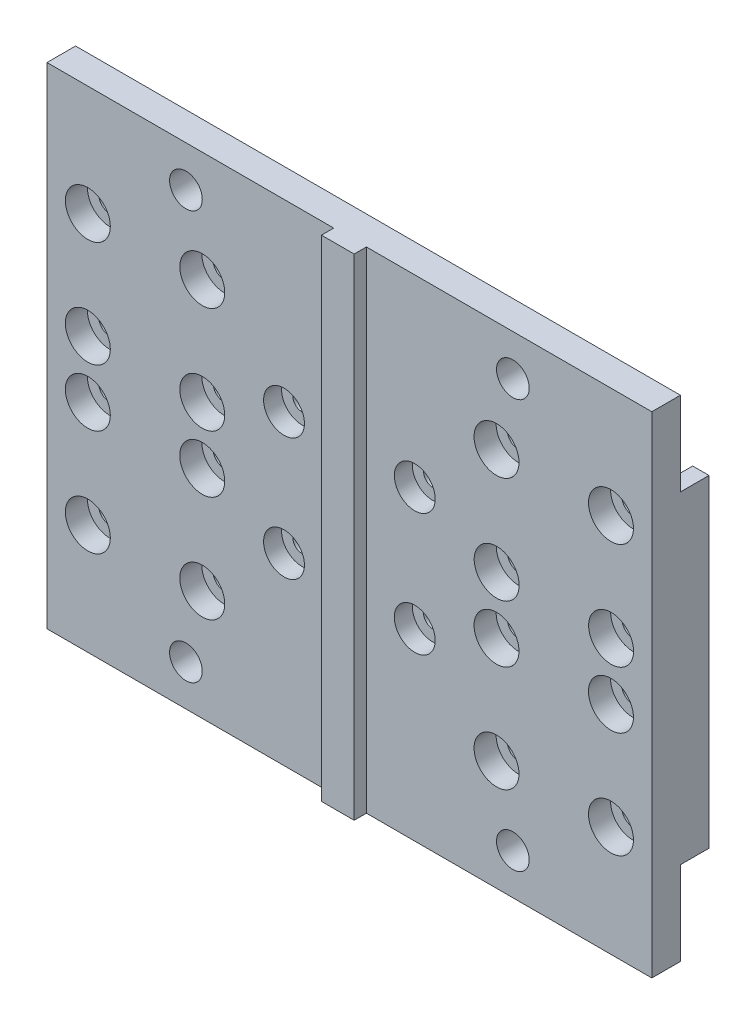
from build123d import *

# Parameters (mm, degrees)
ESQUISSE1_W                                        = 148
ESQUISSE1_H                                        = 120
ESQUISSE1_R                                        = 2.5
ESQUISSE1_R_2                                      = 2
EXTRUSION1_DEPTH                                   = 4
ESQUISSE2_R                                        = 4
ENL_V_MAT_EXTRU_1_DEPTH                            = 100.49847838
ESQUISSE3_W                                        = 148
ESQUISSE3_H                                        = 120
BOSS_EXTRU_1_DEPTH                                 = 3
CHAMBRAGE_POUR_VIS_T_TE_HEXAGONALE_M41_D           = 4.5
CHAMBRAGE_POUR_VIS_T_TE_HEXAGONALE_M41_CBORE_D     = 10
CHAMBRAGE_POUR_VIS_T_TE_HEXAGONALE_M41_CBORE_DEPTH = 4.4
CHAMBRAGE_POUR_VIS_T_TE_HEXAGONALE_M51_D           = 5.5
CHAMBRAGE_POUR_VIS_T_TE_HEXAGONALE_M51_CBORE_D     = 11
CHAMBRAGE_POUR_VIS_T_TE_HEXAGONALE_M51_CBORE_DEPTH = 5.4
ESQUISSE8_R                                        = 4
ENL_V_MAT_EXTRU_2_DEPTH                            = 100.664172098
BOSS_EXTRU_2_START                                 = 4
ESQUISSE9_W                                        = 148
ESQUISSE9_H                                        = 120
ESQUISSE9_R                                        = 2.75
ESQUISSE9_R_2                                      = 2.25
BOSS_EXTRU_2_DEPTH                                 = 4
ESQUISSE11_W                                       = 8
ESQUISSE11_H                                       = 120
BOSS_EXTRU_4_DEPTH                                 = 3
ESQUISSE12_R                                       = 4
ENL_V_MAT_EXTRU_3_DEPTH                            = 100.919703762
ESQUISSE13_R                                       = 2.75
ENL_V_MAT_EXTRU_4_DEPTH                            = 100.919703762
ESQUISSE14_W                                       = 148
ESQUISSE14_H                                       = 20.5
ENL_V_MAT_EXTRU_5_DEPTH                            = 4
ESQUISSE15_W                                       = 4
ESQUISSE15_H                                       = 79
ESQUISSE15_W_2                                     = 10
BOSS_EXTRU_5_DEPTH                                 = 3


with BuildPart() as part:
    # Esquisse1 → Extrusion1 (new body)
    with BuildSketch(Plane.XY):
        with Locations((0, 6.392373056)):
            Rectangle(ESQUISSE1_W, ESQUISSE1_H)
        with Locations((-64, -0.607626944)):
            Circle(ESQUISSE1_R, mode=Mode.SUBTRACT)
        with Locations((-36, 39.392373056)):
            Circle(ESQUISSE1_R, mode=Mode.SUBTRACT)
        with Locations((-64, -26.607626944)):
            Circle(ESQUISSE1_R, mode=Mode.SUBTRACT)
        with Locations((-36, -26.607626944)):
            Circle(ESQUISSE1_R, mode=Mode.SUBTRACT)
        with Locations((36, -0.607626944)):
            Circle(ESQUISSE1_R, mode=Mode.SUBTRACT)
        with Locations((64, -0.607626944)):
            Circle(ESQUISSE1_R, mode=Mode.SUBTRACT)
        with Locations((36, -26.607626944)):
            Circle(ESQUISSE1_R, mode=Mode.SUBTRACT)
        with Locations((64, -26.607626944)):
            Circle(ESQUISSE1_R, mode=Mode.SUBTRACT)
        with Locations((-36, -0.607626944)):
            Circle(ESQUISSE1_R, mode=Mode.SUBTRACT)
        with Locations((-64, 39.392373056)):
            Circle(ESQUISSE1_R, mode=Mode.SUBTRACT)
        with Locations((16, 21.392373056)):
            Circle(ESQUISSE1_R_2, mode=Mode.SUBTRACT)
        with Locations((16, -8.607626944)):
            Circle(ESQUISSE1_R_2, mode=Mode.SUBTRACT)
        with Locations((-16, 21.392373056)):
            Circle(ESQUISSE1_R_2, mode=Mode.SUBTRACT)
        with Locations((-16, -8.607626944)):
            Circle(ESQUISSE1_R_2, mode=Mode.SUBTRACT)
        with Locations((-64, 13.392373056)):
            Circle(ESQUISSE1_R, mode=Mode.SUBTRACT)
        with Locations((-36, 13.392373056)):
            Circle(ESQUISSE1_R, mode=Mode.SUBTRACT)
        with Locations((36, 39.392373056)):
            Circle(ESQUISSE1_R, mode=Mode.SUBTRACT)
        with Locations((36, 13.392373056)):
            Circle(ESQUISSE1_R, mode=Mode.SUBTRACT)
        with Locations((64, 39.392373056)):
            Circle(ESQUISSE1_R, mode=Mode.SUBTRACT)
        with Locations((64, 13.392373056)):
            Circle(ESQUISSE1_R, mode=Mode.SUBTRACT)
    extrude(amount=EXTRUSION1_DEPTH)

    # Esquisse2 → Enlèv. mat.-Extru.1 (cut, through all)
    with BuildSketch(Plane.XY.offset(4)):
        with Locations((-40, 56.392373056)):
            Circle(ESQUISSE2_R)
        with Locations((-40, -43.607626944)):
            Circle(ESQUISSE2_R)
        with Locations((40, 56.392373056)):
            Circle(ESQUISSE2_R)
        with Locations((40, -43.607626944)):
            Circle(ESQUISSE2_R)
    extrude(amount=-ENL_V_MAT_EXTRU_1_DEPTH, mode=Mode.SUBTRACT)

    # Esquisse3 → Boss.-Extru.1 (add)
    with BuildSketch(Plane.XY.offset(4)):
        with Locations((0, 6.392373056)):
            Rectangle(ESQUISSE3_W, ESQUISSE3_H)
    extrude(amount=BOSS_EXTRU_1_DEPTH)

    # Chambrage pour vis à tête hexagonale M41 (through all)
    with Locations(Plane.XY.offset(7)):
        with Locations((-16, 21.392373056), (16, 21.392373056), (16, -8.607626944), (-16, -8.607626944)):
            CounterBoreHole(CHAMBRAGE_POUR_VIS_T_TE_HEXAGONALE_M41_D / 2, CHAMBRAGE_POUR_VIS_T_TE_HEXAGONALE_M41_CBORE_D / 2, CHAMBRAGE_POUR_VIS_T_TE_HEXAGONALE_M41_CBORE_DEPTH)

    # Chambrage pour vis à tête hexagonale M51 (through all)
    with Locations(Plane.XY.offset(7)):
        with Locations((-64, -0.607626944), (-36, -0.607626944), (-36, -26.607626944), (-64, -26.607626944), (36, -0.607626944), (64, -0.607626944), (64, -26.607626944), (36, -26.607626944), (-64, 39.392373056), (-36, 39.392373056), (-64.000489538, 13.39237306), (-36.000489538, 13.39237306), (36, 39.392373056), (64, 39.392373056), (36.038364675, 13.39240136), (64.038364675, 13.392373056)):
            CounterBoreHole(CHAMBRAGE_POUR_VIS_T_TE_HEXAGONALE_M51_D / 2, CHAMBRAGE_POUR_VIS_T_TE_HEXAGONALE_M51_CBORE_D / 2, CHAMBRAGE_POUR_VIS_T_TE_HEXAGONALE_M51_CBORE_DEPTH)

    # Esquisse8 → Enlèv. mat.-Extru.2 (cut, through all)
    with BuildSketch(Plane(origin=(0, 0, 0), x_dir=(-1, 0, 0), z_dir=(0, 0, -1))):
        with Locations(Location((40, -43.607626944, 0), (0, 0, 180))):
            Circle(ESQUISSE8_R)
        with Locations(Location((40, 56.392373056, 0), (0, 0, 180))):
            Circle(ESQUISSE8_R)
        with Locations(Location((-40, 56.392373056, 0), (0, 0, 180))):
            Circle(ESQUISSE8_R)
        with Locations(Location((-40, -43.607626944, 0), (0, 0, 180))):
            Circle(ESQUISSE8_R)
    extrude(amount=-ENL_V_MAT_EXTRU_2_DEPTH, mode=Mode.SUBTRACT)

    # Esquisse9 → Boss.-Extru.2 (add)
    with BuildSketch(Plane(origin=(0, 0, 0), x_dir=(-1, 0, 0), z_dir=(0, 0, -1)).offset(BOSS_EXTRU_2_START)):
        with Locations((0, 6.392373056)):
            Rectangle(ESQUISSE9_W, ESQUISSE9_H)
        with Locations(Location((-64, -0.607626944, 0), (0, 0, 180))):
            Circle(ESQUISSE9_R, mode=Mode.SUBTRACT)
        with Locations(Location((-64, -26.607626944, 0), (0, 0, 180))):
            Circle(ESQUISSE9_R, mode=Mode.SUBTRACT)
        with Locations(Location((-36, -0.607626944, 0), (0, 0, 180))):
            Circle(ESQUISSE9_R, mode=Mode.SUBTRACT)
        with Locations(Location((-36, -26.607626944, 0), (0, 0, 180))):
            Circle(ESQUISSE9_R, mode=Mode.SUBTRACT)
        with Locations(Location((-16, 21.392373056, 0), (0, 0, 180))):
            Circle(ESQUISSE9_R_2, mode=Mode.SUBTRACT)
        with Locations(Location((16, 21.392373056, 0), (0, 0, 180))):
            Circle(ESQUISSE9_R_2, mode=Mode.SUBTRACT)
        with Locations(Location((-16, -8.607626944, 0), (0, 0, 180))):
            Circle(ESQUISSE9_R_2, mode=Mode.SUBTRACT)
        with Locations(Location((16, -8.607626944, 0), (0, 0, 180))):
            Circle(ESQUISSE9_R_2, mode=Mode.SUBTRACT)
        with Locations(Location((36, -0.607626944, 0), (0, 0, 180))):
            Circle(ESQUISSE9_R, mode=Mode.SUBTRACT)
        with Locations(Location((64, -0.607626944, 0), (0, 0, 180))):
            Circle(ESQUISSE9_R, mode=Mode.SUBTRACT)
        with Locations(Location((36, -26.607626944, 0), (0, 0, 180))):
            Circle(ESQUISSE9_R, mode=Mode.SUBTRACT)
        with Locations(Location((64, -26.607626944, 0), (0, 0, 180))):
            Circle(ESQUISSE9_R, mode=Mode.SUBTRACT)
    extrude(amount=-BOSS_EXTRU_2_DEPTH)

    # Esquisse11 → Boss.-Extru.4 (add)
    with BuildSketch(Plane.XY.offset(7)):
        with Locations((0.163625215, 6.392373056)):
            Rectangle(ESQUISSE11_W, ESQUISSE11_H)
    extrude(amount=BOSS_EXTRU_4_DEPTH)

    # Esquisse12 → Enlèv. mat.-Extru.3 (cut, through all)
    with BuildSketch(Plane.XY):
        with Locations((-40, 56.392373056)):
            Circle(ESQUISSE12_R)
        with Locations((40, 56.392373056)):
            Circle(ESQUISSE12_R)
        with Locations((40, -43.607626944)):
            Circle(ESQUISSE12_R)
        with Locations((-40, -43.607626944)):
            Circle(ESQUISSE12_R)
    extrude(amount=-ENL_V_MAT_EXTRU_3_DEPTH, mode=Mode.SUBTRACT)

    # Esquisse13 → Enlèv. mat.-Extru.4 (cut, through all)
    with BuildSketch(Plane.XY):
        with Locations((-64, 39.392373056)):
            Circle(ESQUISSE13_R)
        with Locations((-36, 39.392373056)):
            Circle(ESQUISSE13_R)
        with Locations((-36.000489538, 13.39237306)):
            Circle(ESQUISSE13_R)
        with Locations((-64.000489538, 13.39237306)):
            Circle(ESQUISSE13_R)
        with Locations((36, 39.392373056)):
            Circle(ESQUISSE13_R)
        with Locations((64, 39.392373056)):
            Circle(ESQUISSE13_R)
        with Locations((36.038364675, 13.39240136)):
            Circle(ESQUISSE13_R)
        with Locations((64.038364675, 13.392373056)):
            Circle(ESQUISSE13_R)
    extrude(amount=-ENL_V_MAT_EXTRU_4_DEPTH, mode=Mode.SUBTRACT)

    # Esquisse14 → Enlèv. mat.-Extru.5 (cut)
    with BuildSketch(Plane(origin=(0, 0, -4), x_dir=(-1, 0, 0), z_dir=(0, 0, -1))):
        with Locations((0, -43.357626944)):
            Rectangle(ESQUISSE14_W, ESQUISSE14_H)
        with Locations((0, 56.142373056)):
            Rectangle(ESQUISSE14_W, ESQUISSE14_H)
    extrude(amount=-ENL_V_MAT_EXTRU_5_DEPTH, mode=Mode.SUBTRACT)

    # Esquisse15 → Boss.-Extru.5 (add)
    with BuildSketch(Plane(origin=(0, 0, -4), x_dir=(-1, 0, 0), z_dir=(0, 0, -1))):
        with Locations((-72, 6.392373056)):
            Rectangle(ESQUISSE15_W, ESQUISSE15_H)
        with Locations((-25, 6.392373056)):
            Rectangle(ESQUISSE15_W_2, ESQUISSE15_H)
        with Locations((25, 6.392373056)):
            Rectangle(ESQUISSE15_W_2, ESQUISSE15_H)
        with Locations((72, 6.392373056)):
            Rectangle(ESQUISSE15_W, ESQUISSE15_H)
    extrude(amount=BOSS_EXTRU_5_DEPTH)


solid = part.part
